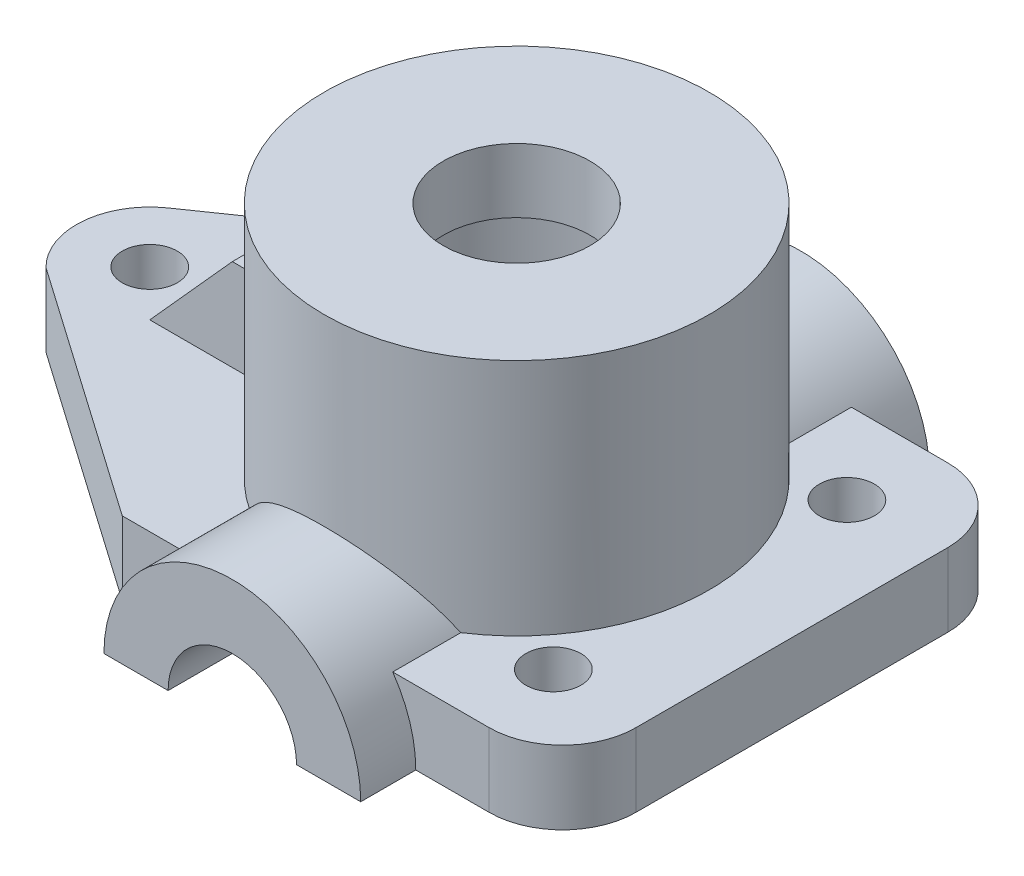
from build123d import *

# Parameters (mm, degrees)
EXTRUDE_1_DEPTH      = 31
EXTRUDE_1_DEPTH_BACK = 31
SKETCH_2_R           = 21
EXTRUDE_2_DEPTH      = 34
EXTRUDE_3_DEPTH      = 8
EXTRUDE_4_DEPTH      = 8
EXTRUDE_5_DEPTH      = 5
EXTRUDE_5_DEPTH_BACK = 5
SKETCH_6_R           = 8
CUT_EXTRUDE_1_DEPTH  = 7
SKETCH_7_R           = 15
CUT_EXTRUDE_2_DEPTH  = 64.198101329
SKETCH_8_R           = 7
CUT_EXTRUDE_3_DEPTH  = 86.463442589
SKETCH_9_R           = 3
CUT_EXTRUDE_4_DEPTH  = 63.777384554


with BuildPart() as part:
    # 草图1 → 凸台-拉伸1 (new, two sides: drawn at the far end of the back side and taken through both)
    with BuildSketch(Plane.XY.offset(-EXTRUDE_1_DEPTH_BACK)):
        with BuildLine():
            Line((-14, 0), (14, 0))
            ThreePointArc((14, 0), (0, 14), (-14, 0))
        make_face()
    extrude(amount=EXTRUDE_1_DEPTH + EXTRUDE_1_DEPTH_BACK)

    # 草图2 → 凸台-拉伸2 (add)
    with BuildSketch(Plane(origin=(0, 0, 0), x_dir=(1, 0, 0), z_dir=(0, 1, 0))):
        Circle(SKETCH_2_R)
    extrude(amount=EXTRUDE_2_DEPTH)

    # 草图3 → 凸台-拉伸3 (add)
    with BuildSketch(Plane(origin=(0, 0, 0), x_dir=(1, 0, 0), z_dir=(0, 1, 0))):
        with BuildLine():
            Line((0, 25), (0, -25))
            Line((0, -25), (-18, -25))
            Line((-18, -25), (-45.582150825, -5.730583929))
            ThreePointArc((-45.582150825, -5.730583929), (-47.97254676, 0.662191934), (-44.560227187, 6.572999924))
            Line((-44.560227187, 6.572999924), (-18, 25))
            Line((-18, 25), (0, 25))
        make_face()
    extrude(amount=EXTRUDE_3_DEPTH)

    # 草图4 → 凸台-拉伸4 (add)
    with BuildSketch(Plane(origin=(0, 0, 0), x_dir=(1, 0, 0), z_dir=(0, 1, 0))):
        with BuildLine():
            Line((0, -25), (0, 25))
            Line((0, 25), (22, 25))
            ThreePointArc((22, 25), (27.656854249, 22.656854249), (30, 17))
            Line((30, 17), (30, -17))
            ThreePointArc((30, -17), (27.656854249, -22.656854249), (22, -25))
            Line((22, -25), (0, -25))
        make_face()
    extrude(amount=EXTRUDE_4_DEPTH)

    # 草图5 → 凸台-拉伸5 (add, two sides: drawn at the far end of the back side and taken through both)
    with BuildSketch(Plane.XY.offset(-EXTRUDE_5_DEPTH_BACK)):
        Polygon((-16.636065675, 8), (-35, 8), (-26, 18), (-16.636065675, 18), align=None)
    extrude(amount=EXTRUDE_5_DEPTH + EXTRUDE_5_DEPTH_BACK)

    # 草图6 → 切除-拉伸1 (cut)
    with BuildSketch(Plane(origin=(0, 34, 0), x_dir=(1, 0, 0), z_dir=(0, 1, 0))):
        Circle(SKETCH_6_R)
    extrude(amount=-CUT_EXTRUDE_1_DEPTH, mode=Mode.SUBTRACT)

    # 草图7 → 切除-拉伸2 (cut, through all)
    with BuildSketch(Plane(origin=(0, 27, 0), x_dir=(1, 0, 0), z_dir=(0, 1, 0))):
        Circle(SKETCH_7_R)
    extrude(amount=-CUT_EXTRUDE_2_DEPTH, mode=Mode.SUBTRACT)

    # 草图8 → 切除-拉伸3 (cut, through all)
    with BuildSketch(Plane.XY.offset(31)):
        Circle(SKETCH_8_R)
    extrude(amount=-CUT_EXTRUDE_3_DEPTH, mode=Mode.SUBTRACT)

    # 草图9 → 切除-拉伸4 (cut, through all)
    with BuildSketch(Plane(origin=(0, 8, 0), x_dir=(1, 0, 0), z_dir=(0, 1, 0))):
        with Locations((-40, 0)):
            Circle(SKETCH_9_R)
        with Locations((20, 16)):
            Circle(SKETCH_9_R)
        with Locations((20, -16)):
            Circle(SKETCH_9_R)
    extrude(amount=-CUT_EXTRUDE_4_DEPTH, mode=Mode.SUBTRACT)


solid = part.part
